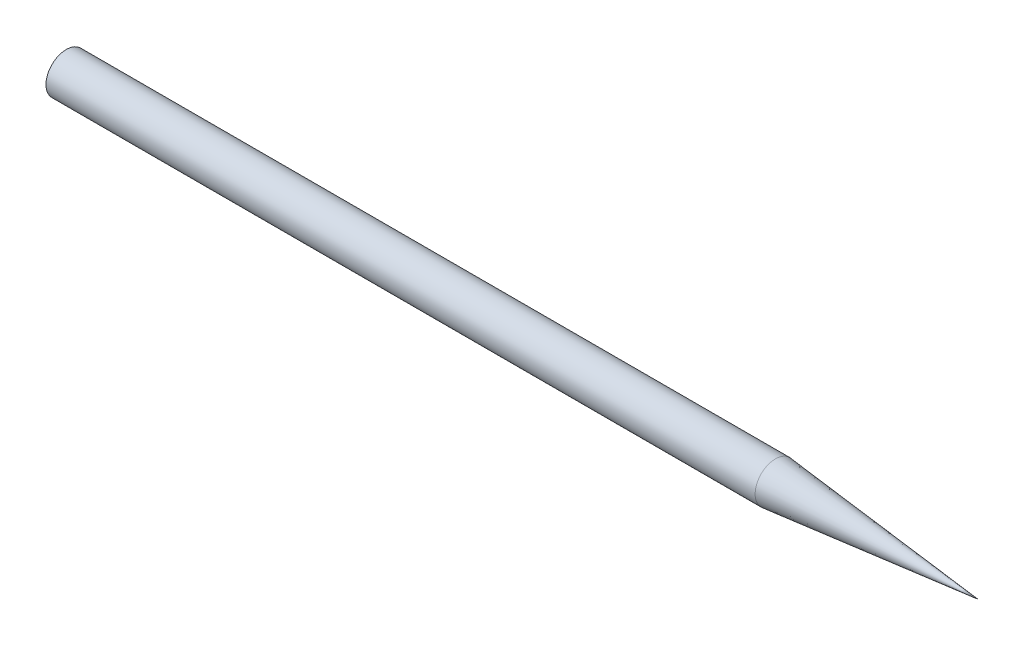
from build123d import *


with BuildPart() as part:
    # Sketch1 → Revolve1 (revolve)
    with BuildSketch(Plane.XY):
        Polygon((-67.5, 0), (67.5, 0), (37.5, 3), (-67.5, 3), align=None)
    revolve(axis=Axis((-67.5, 0, 0), (1, 0, 0)))


solid = part.part
